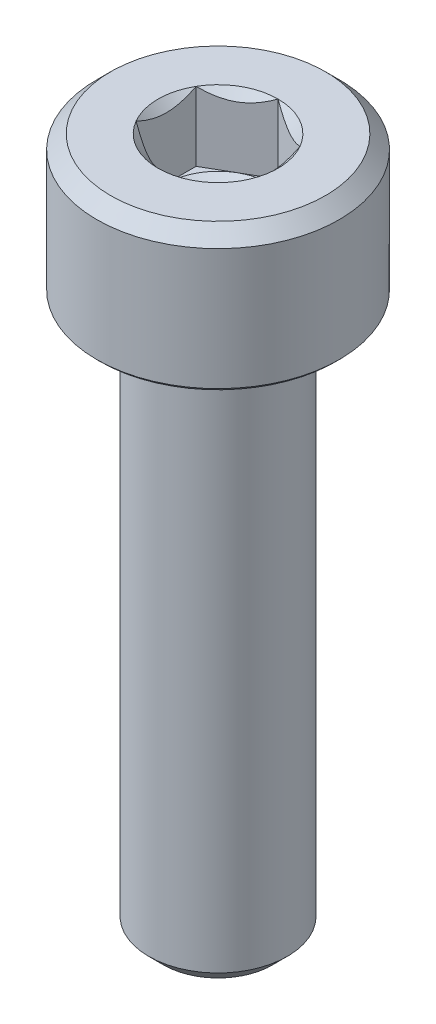
from build123d import *

# Parameters (mm, degrees)
CUT_EXTRUDE1_DEPTH = 2


with BuildPart() as part:
    # Sketch1 → Revolve1 (revolve)
    with BuildSketch(Plane.XY):
        Polygon((0, 1.133974596), (1.5, 2), (1.5, 3.767949192), (1.732050808, 4), (3.1, 4), (3.5, 3.6), (3.5, 0.1), (3.4, 0), (2.05, 0), (2, -0.6), (2, -15.5705), (1.5705, -16), (0, -16), align=None)
    revolve(axis=Axis((0, -16, 0), (0, 1, 0)))

    # Sketch2 → Cut-Extrude1 (cut)
    with BuildSketch(Plane(origin=(0, 4, 0), x_dir=(1, 0, 0), z_dir=(0, 1, 0))):
        Polygon((-1.5, -0.866025404), (0, -1.732050808), (1.5, -0.866025404), (1.5, 0.866025404), (0, 1.732050808), (-1.5, 0.866025404), align=None)
    extrude(amount=-CUT_EXTRUDE1_DEPTH, mode=Mode.SUBTRACT)


solid = part.part
